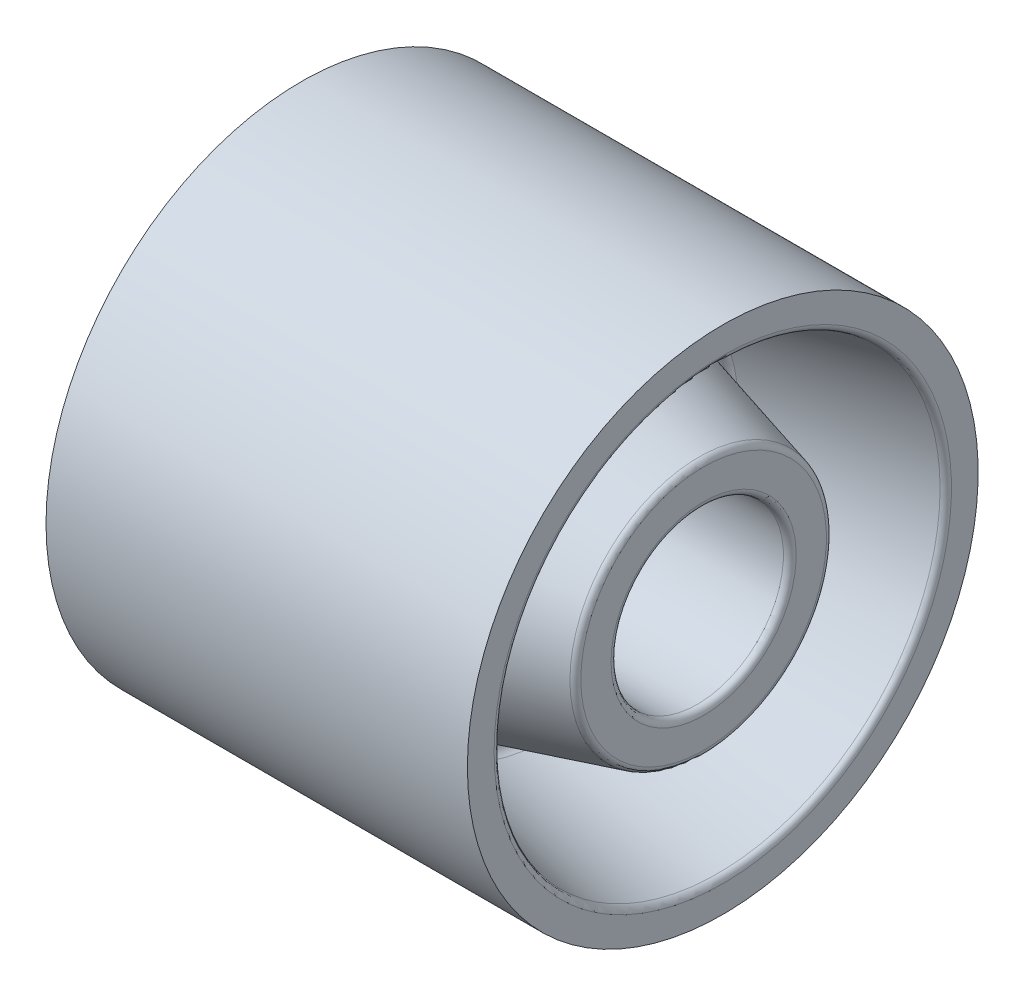
from build123d import *

# Parameters (mm, degrees)
FILLET1_R = 1


with BuildPart() as part:
    # Sketch1 → Revolve1 (revolve)
    with BuildSketch(Plane.XY):
        with BuildLine():
            Line((-30, 13.5), (30, 13.5))
            Line((30, 13.5), (30, 20))
            Line((30, 20), (5.610867889, 26.551353666))
            ThreePointArc((5.610867889, 26.551353666), (4.512893834, 28.196253025), (6, 29.5))
            Line((6, 29.5), (33, 35))
            Line((33, 35), (33, 40))
            Line((33, 40), (-33, 40))
            Line((-33, 40), (-33, 35))
            Line((-33, 35), (-6, 29.5))
            ThreePointArc((-6, 29.5), (-4.512893834, 28.196253025), (-5.610867889, 26.551353666))
            Line((-5.610867889, 26.551353666), (-30, 20))
            Line((-30, 20), (-30, 13.5))
        make_face()
    revolve(axis=Axis((-33, 0, 0), (1, 0, 0)))

    # Fillet1
    fillet1_edges = [part.edges().sort_by_distance(p)[0] for p in [
        (-33, -35, 0),
        (33, -35, 0),
        (30, -20, 0),
        (30, -13.5, 0),
        (-30, -13.5, 0),
        (-30, -20, 0),
    ]]
    fillet(fillet1_edges, radius=FILLET1_R)


solid = part.part
